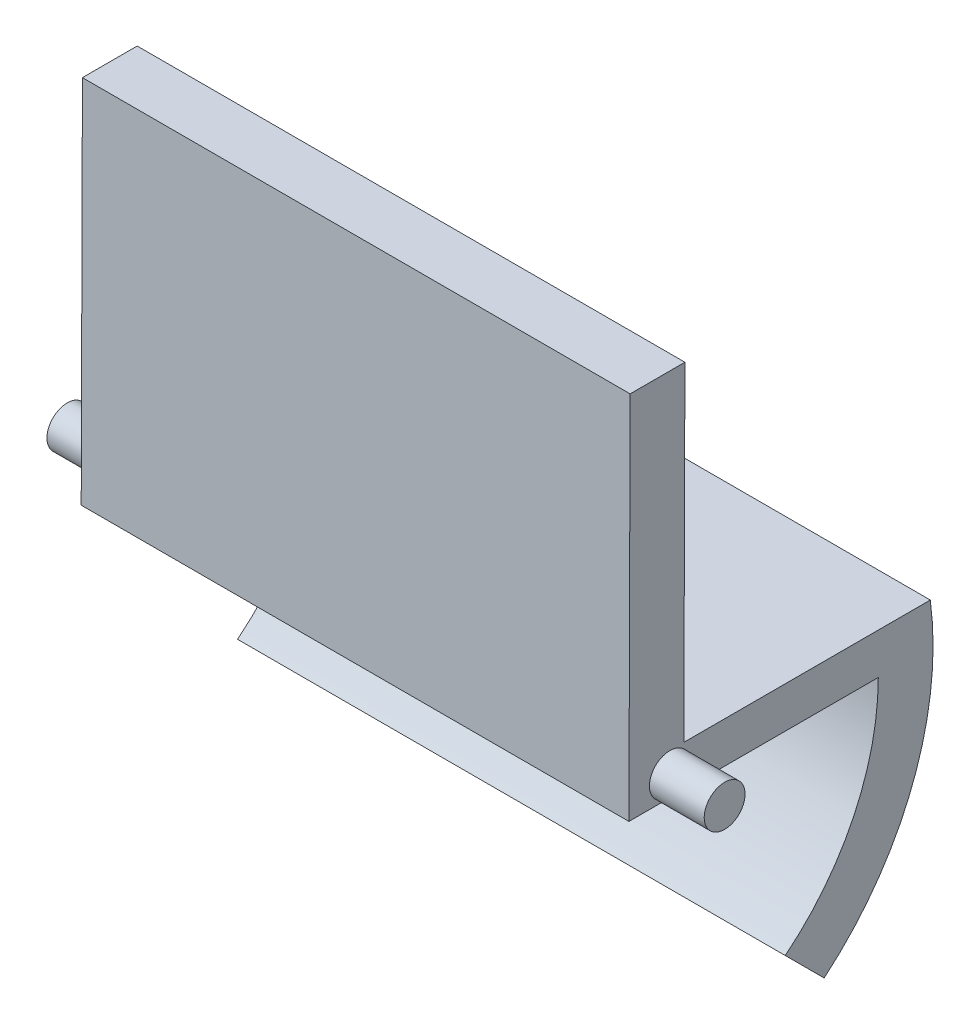
from build123d import *

# Parameters (mm, degrees)
BOSS_EXTRU_1_DEPTH      = 100
ESQUISSE3_R             = 3.73
BOSS_EXTRU_2_DEPTH      = 10
BOSS_EXTRU_2_DEPTH_BACK = 110


with BuildPart() as part:
    # Esquisse1 → Boss.-Extru.1 (new body)
    with BuildSketch(Plane(origin=(0, 0, 0), x_dir=(0, 0, -1), z_dir=(1, 0, 0))):
        with BuildLine():
            Line((11.916237197, -42.931206961), (19.021149864, -50.036119628))
            ThreePointArc((19.021149864, -50.036119628), (35.155991103, -27.514297721), (38.400830806, 0))
            Line((38.400830806, 0), (38.400830806, 0.038210025))
            Line((38.400830806, 0.038210025), (-6.599169194, 0.038210025))
            Line((-6.599169194, 0.038210025), (-6.402631947, 60.038210025))
            Line((-6.402631947, 60.038210025), (-16.402685595, 60.038210025))
            Line((-16.402685595, 60.038210025), (-16.623781762, -7.459275773))
            Line((-16.623781762, -7.459275773), (28.904128187, -7.459275773))
            ThreePointArc((28.904128187, -7.459275773), (24.438110532, -27.124259516), (11.916237197, -42.931206961))
        make_face()
    extrude(amount=BOSS_EXTRU_1_DEPTH)

    # Esquisse3 → Boss.-Extru.2 (add, two sides)
    with BuildSketch(Plane.ZY) as boss_extru_2_sk:
        with Locations((9.151523675, -3.729275773)):
            Circle(ESQUISSE3_R)
    extrude(amount=BOSS_EXTRU_2_DEPTH)
    extrude(boss_extru_2_sk.sketch, amount=-BOSS_EXTRU_2_DEPTH_BACK)


solid = part.part
